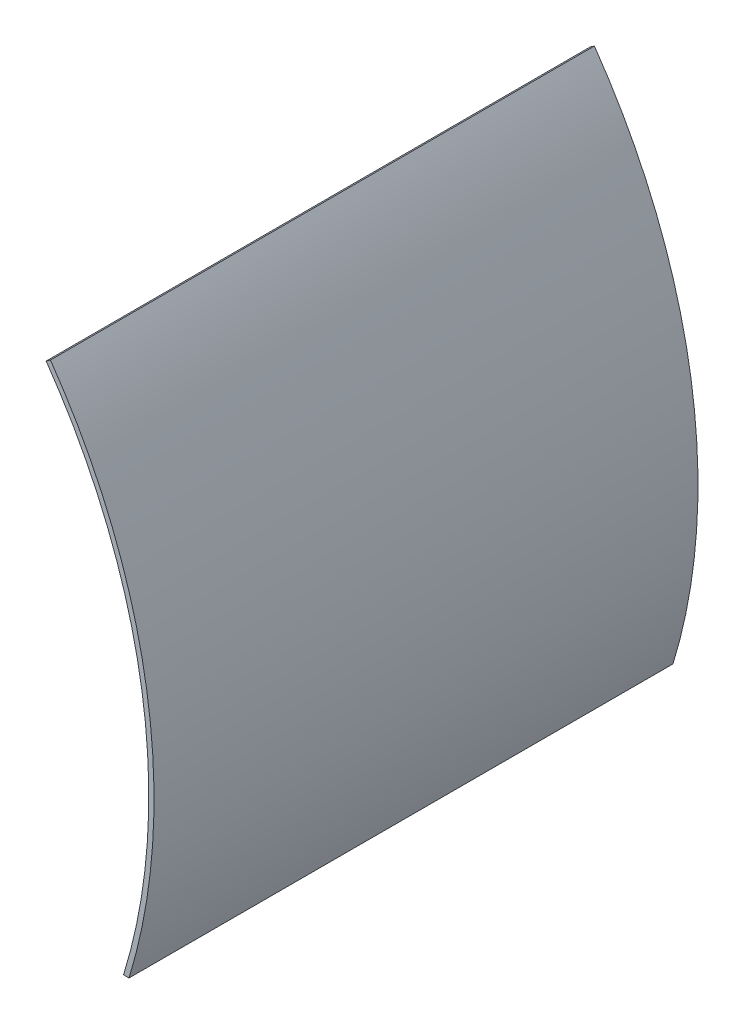
from build123d import *

# Parameters (mm, degrees)
BOSS_EXTRUDE1_DEPTH = 165.1


with BuildPart() as part:
    # Sketch1 → Boss-Extrude1 (new body)
    with BuildSketch(Plane.XY):
        with BuildLine():
            Line((141.093819929, 98.794956309), (142.394223799, 99.705508901))
            ThreePointArc((142.394223799, 99.705508901), (165.785809695, 52.27206501), (173.83125, 0))
            ThreePointArc((173.83125, 0), (171.923667002, -25.681826284), (166.242784735, -50.8))
            Line((166.242784735, -50.8), (164.582105388, -50.8))
            ThreePointArc((164.582105388, -50.8), (170.31756872, -25.687257532), (172.24375, 0))
            ThreePointArc((172.24375, 0), (164.271784035, 51.794694553), (141.093819929, 98.794956309))
        make_face()
    extrude(amount=BOSS_EXTRUDE1_DEPTH)


solid = part.part
